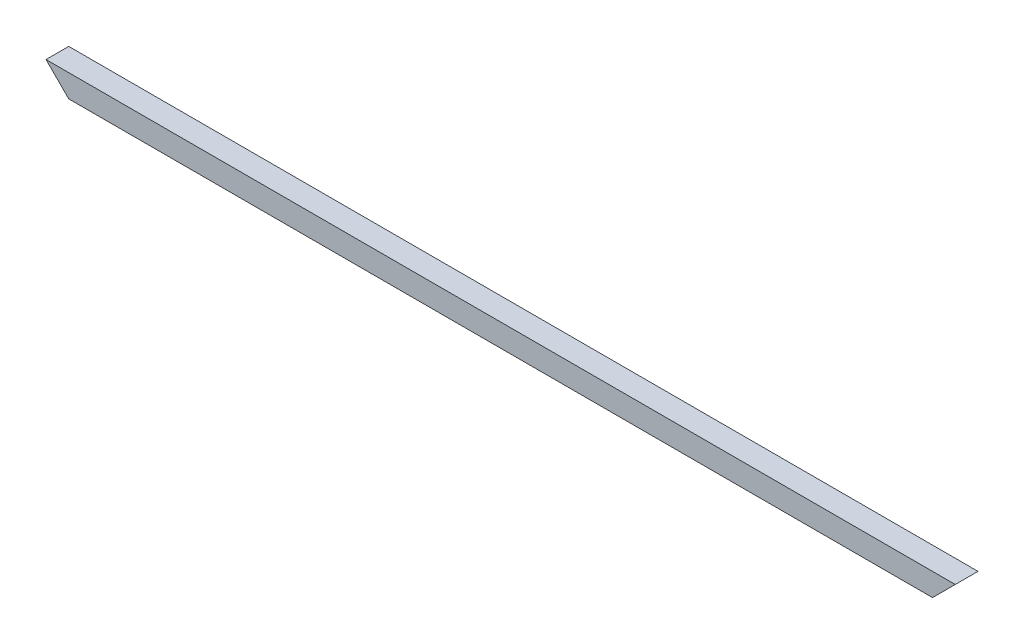
from build123d import *

# Parameters (mm, degrees)
SKETCH1_W               = 20
SKETCH1_H               = 20
SKETCH1_W_2             = 17.6
SKETCH1_H_2             = 17.6
BOSS_EXTRUDE1_DEPTH     = 800
CUT_EXTRUDE1_DEPTH      = 1
CUT_EXTRUDE1_DEPTH_BACK = 21
CUT_EXTRUDE2_DEPTH      = 1
CUT_EXTRUDE2_DEPTH_BACK = 21


with BuildPart() as part:
    # Sketch1 → Boss-Extrude1 (new body)
    with BuildSketch(Plane(origin=(0, 0, 0), x_dir=(0, 0, -1), z_dir=(1, 0, 0))):
        Rectangle(SKETCH1_W, SKETCH1_H)
        Rectangle(SKETCH1_W_2, SKETCH1_H_2, mode=Mode.SUBTRACT)
    extrude(amount=BOSS_EXTRUDE1_DEPTH)

    # Sketch2 → Cut-Extrude1 (cut, two sides)
    with BuildSketch(Plane.XY.offset(10)) as cut_extrude1_sk:
        Polygon((-1138.795415875, 1148.795415875), (0, 10), (20, -10), (1158.795415875, -1148.795415875), (-1118.795415875, -3426.386247626), (-3416.386247626, -1128.795415876), align=None)
    extrude(amount=CUT_EXTRUDE1_DEPTH, mode=Mode.SUBTRACT)
    extrude(cut_extrude1_sk.sketch, amount=-CUT_EXTRUDE1_DEPTH_BACK, mode=Mode.SUBTRACT)

    # Sketch3 → Cut-Extrude2 (cut, two sides)
    with BuildSketch(Plane.XY.offset(10)) as cut_extrude2_sk:
        Polygon((1938.795415875, 1148.795415875), (800, 10), (780, -10), (-358.795415875, -1148.795415875), (1918.795415876, -3426.386247626), (4216.386247626, -1128.795415875), align=None)
    extrude(amount=CUT_EXTRUDE2_DEPTH, mode=Mode.SUBTRACT)
    extrude(cut_extrude2_sk.sketch, amount=-CUT_EXTRUDE2_DEPTH_BACK, mode=Mode.SUBTRACT)


solid = part.part
